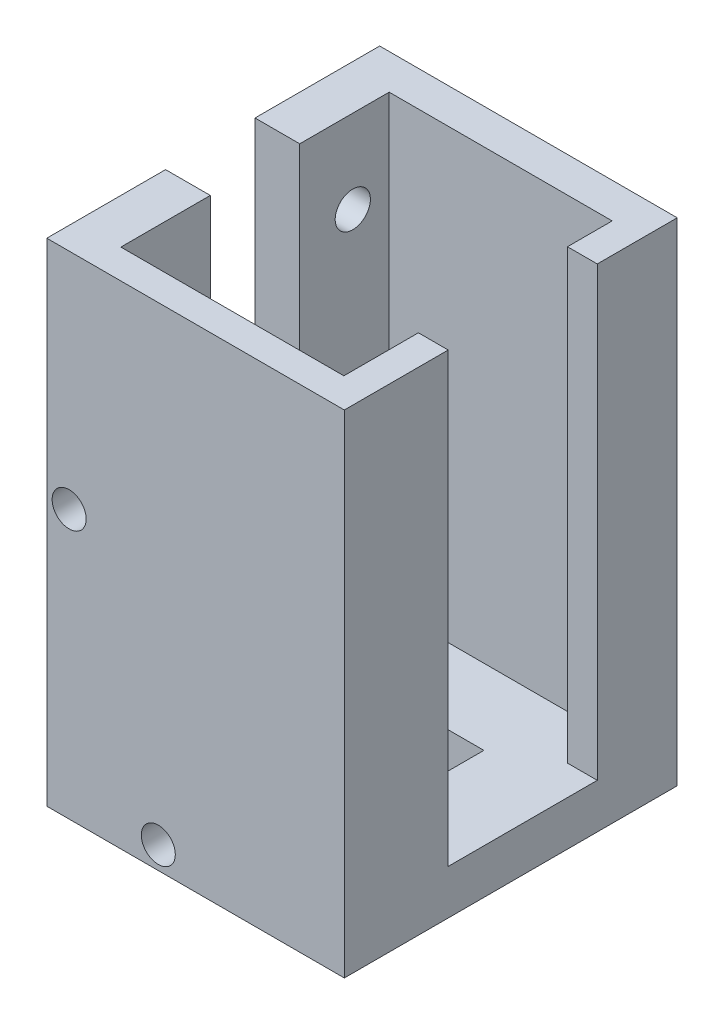
from build123d import *

# Parameters (mm, degrees)
BOSS_EXTRUDE2_DEPTH = 38.1
SKETCH1_W           = 25.35
SKETCH1_H           = 28.36
BOSS_EXTRUDE3_DEPTH = 3.81
SKETCH3_W           = 10
SKETCH3_H           = 10
CUT_EXTRUDE1_DEPTH  = 43.860132991
SKETCH4_W           = 7.62
SKETCH4_H           = 30.1
CUT_EXTRUDE2_DEPTH  = 47.084775143
SKETCH5_R           = 1.5
CUT_EXTRUDE3_DEPTH  = 47.084775143
SKETCH6_R           = 1.45
CUT_EXTRUDE4_DEPTH  = 24.344


with BuildPart() as part:
    # Sketch2 → Boss-Extrude2 (new body)
    with BuildSketch(Plane(origin=(0, 0, 0), x_dir=(1, 0, 0), z_dir=(0, 1, 0))):
        Polygon((-9.5, -11.43), (9.5, -11.43), (9.5, -5.08), (12.04, -5.08), (12.04, -13.93), (-13.31, -13.93), (-13.31, 14.43), (12.04, 14.43), (12.04, 7.62), (9.5, 7.62), (9.5, 11.43), (-9.5, 11.43), align=None)
    extrude(amount=BOSS_EXTRUDE2_DEPTH)

    # Sketch1 → Boss-Extrude3 (add)
    with BuildSketch(Plane(origin=(0, 0, 0), x_dir=(1, 0, 0), z_dir=(0, 1, 0))):
        with Locations((-0.635, 0.25)):
            Rectangle(SKETCH1_W, SKETCH1_H)
    extrude(amount=-BOSS_EXTRUDE3_DEPTH)

    # Sketch3 → Cut-Extrude1 (cut, through all)
    with BuildSketch(Plane(origin=(0, 0, 0), x_dir=(1, 0, 0), z_dir=(0, 1, 0))):
        Rectangle(SKETCH3_W, SKETCH3_H)
    extrude(amount=-CUT_EXTRUDE1_DEPTH, mode=Mode.SUBTRACT)

    # Sketch4 → Cut-Extrude2 (cut, through all)
    with BuildSketch(Plane(origin=(-9.5, 0, 0), x_dir=(0, 0, -1), z_dir=(1, 0, 0))):
        with Locations((0, 23.05)):
            Rectangle(SKETCH4_W, SKETCH4_H)
    extrude(amount=-CUT_EXTRUDE2_DEPTH, mode=Mode.SUBTRACT)

    # Sketch5 → Cut-Extrude3 (cut, through all)
    with BuildSketch(Plane(origin=(-9.5, 0, 0), x_dir=(0, 0, -1), z_dir=(1, 0, 0))):
        with Locations((-9.1700096, 31)):
            Circle(SKETCH5_R)
        with Locations((8.3299904, 31)):
            Circle(SKETCH5_R)
    extrude(amount=-CUT_EXTRUDE3_DEPTH, mode=Mode.SUBTRACT)

    # Sketch6 → Cut-Extrude4 (cut)
    with BuildSketch(Plane.XY.offset(13.93)):
        with Locations(Location((-11.405, 19.05, 0), (0, 0, 90))):
            Circle(SKETCH6_R)
        with Locations((-3.81, -1.905)):
            Circle(SKETCH6_R)
    extrude(amount=-CUT_EXTRUDE4_DEPTH, mode=Mode.SUBTRACT)


solid = part.part
